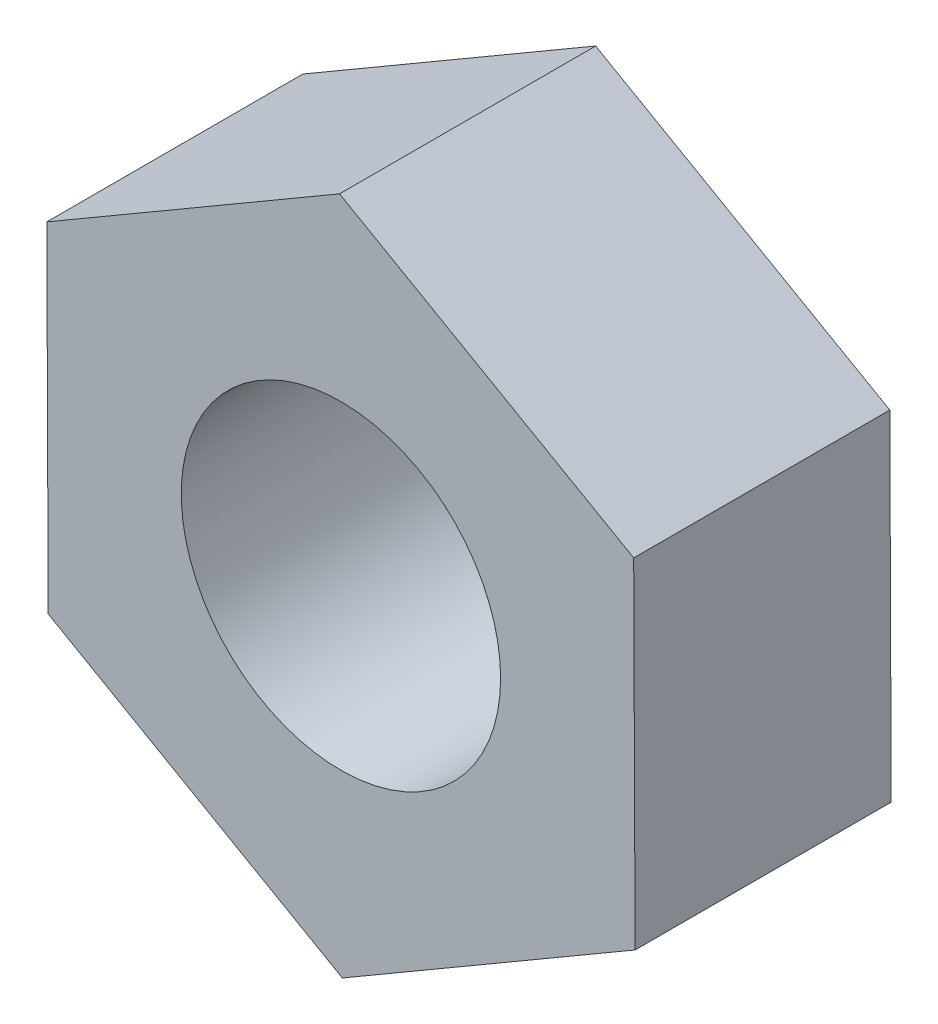
from build123d import *

# Parameters (mm, degrees)
SZKIC1_R                    = 1.496415342
DODANIE_WYCI_GNI_CIE1_DEPTH = 2.4


with BuildPart() as part:
    # Szkic1 → Dodanie-wyciągnięcie1 (new body)
    with BuildSketch(Plane.XY):
        Polygon((2.743428127, 1.599042039), (-0.013096964, 3.175399471), (-2.756525091, 1.576357432), (-2.743428127, -1.599042039), (0.013096964, -3.175399471), (2.756525091, -1.576357432), align=None)
        Circle(SZKIC1_R, mode=Mode.SUBTRACT)
    extrude(amount=DODANIE_WYCI_GNI_CIE1_DEPTH)


solid = part.part
